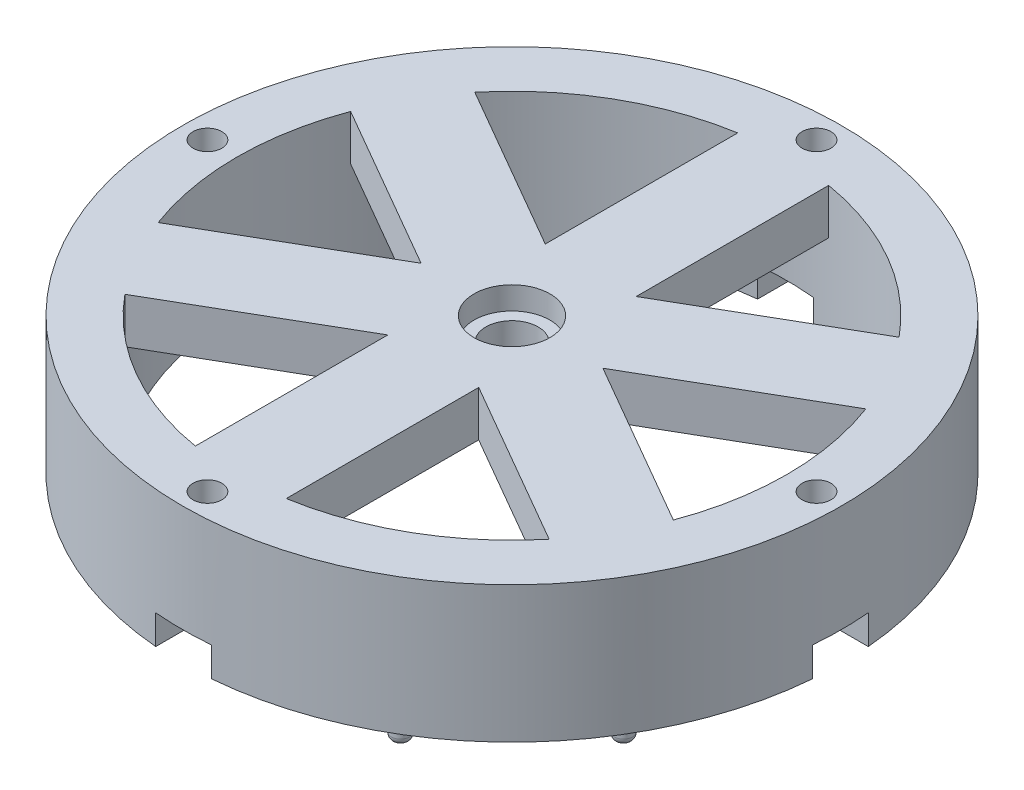
from build123d import *

# Parameters (mm, degrees)
SKETCH1_R               = 72.5
SKETCH1_R_2             = 3.175
BOSS_EXTRUDE1_DEPTH     = 10
SKETCH8_R               = 8.35
CUT_EXTRUDE4_DEPTH      = 5
SKETCH9_R               = 5.75
CUT_EXTRUDE5_DEPTH      = 1
CUT_EXTRUDE5_DEPTH_BACK = 11
SKETCH10_R              = 72.5
SKETCH10_R_2            = 60.5
SKETCH10_R_3            = 3.175
BOSS_EXTRUDE4_DEPTH     = 20
SKETCH11_W              = 32.27284004
SKETCH11_H              = 12.3
SKETCH11_W_2            = 12.3
SKETCH11_H_2            = 32.27284004
CUT_EXTRUDE6_DEPTH      = 6.45
SKETCH12_R              = 2
BOSS_EXTRUDE5_DEPTH     = 5
FILLET1_R               = 1.5


with BuildPart() as part:
    # Sketch1 → Boss-Extrude1 (new body)
    with BuildSketch(Plane(origin=(0, 0, 0), x_dir=(1, 0, 0), z_dir=(0, 1, 0))):
        Circle(SKETCH1_R)
        with Locations((0, 67)):
            Circle(SKETCH1_R_2, mode=Mode.SUBTRACT)
        with Locations((67, 0)):
            Circle(SKETCH1_R_2, mode=Mode.SUBTRACT)
        with Locations((0, -67)):
            Circle(SKETCH1_R_2, mode=Mode.SUBTRACT)
        with Locations((-67, 0)):
            Circle(SKETCH1_R_2, mode=Mode.SUBTRACT)
        with BuildLine():
            Line((10, 17.320508076), (10, 59.667830529))
            ThreePointArc((10, 59.667830529), (30.25, 52.394536929), (46.673857027, 38.494169302))
            Line((46.673857027, 38.494169302), (10, 17.320508076))
        make_face(mode=Mode.SUBTRACT)
        with BuildLine():
            Line((-10, 17.320508076), (-10, 59.667830529))
            ThreePointArc((-10, 59.667830529), (-30.25, 52.394536929), (-46.673857027, 38.494169302))
            Line((-46.673857027, 38.494169302), (-10, 17.320508076))
        make_face(mode=Mode.SUBTRACT)
        with BuildLine():
            Line((-20, 0), (-56.673857027, 21.173661227))
            ThreePointArc((-56.673857027, 21.173661227), (-60.5, 0), (-56.673857027, -21.173661226))
            Line((-56.673857027, -21.173661226), (-20, 0))
        make_face(mode=Mode.SUBTRACT)
        with BuildLine():
            Line((-10, -17.320508076), (-46.673857027, -38.494169302))
            ThreePointArc((-46.673857027, -38.494169302), (-30.25, -52.394536929), (-10, -59.667830529))
            Line((-10, -59.667830529), (-10, -17.320508076))
        make_face(mode=Mode.SUBTRACT)
        with BuildLine():
            Line((10, -17.320508076), (10, -59.667830529))
            ThreePointArc((10, -59.667830529), (30.25, -52.394536929), (46.673857027, -38.494169302))
            Line((46.673857027, -38.494169302), (10, -17.320508076))
        make_face(mode=Mode.SUBTRACT)
        with BuildLine():
            Line((20, 0), (56.673857027, 21.173661227))
            ThreePointArc((56.673857027, 21.173661227), (60.5, 0), (56.673857027, -21.173661226))
            Line((56.673857027, -21.173661226), (20, 0))
        make_face(mode=Mode.SUBTRACT)
    extrude(amount=BOSS_EXTRUDE1_DEPTH)

    # Sketch8 → Cut-Extrude4 (cut)
    with BuildSketch(Plane(origin=(0, 10, 0), x_dir=(1, 0, 0), z_dir=(0, 1, 0))):
        Circle(SKETCH8_R)
    extrude(amount=-CUT_EXTRUDE4_DEPTH, mode=Mode.SUBTRACT)

    # Sketch9 → Cut-Extrude5 (cut, two sides)
    with BuildSketch(Plane(origin=(0, 10, 0), x_dir=(1, 0, 0), z_dir=(0, 1, 0))) as cut_extrude5_sk:
        Circle(SKETCH9_R)
    extrude(amount=CUT_EXTRUDE5_DEPTH, mode=Mode.SUBTRACT)
    extrude(cut_extrude5_sk.sketch, amount=-CUT_EXTRUDE5_DEPTH_BACK, mode=Mode.SUBTRACT)

    # Sketch10 → Boss-Extrude4 (add)
    with BuildSketch(Plane.XZ):
        Circle(SKETCH10_R)
        Circle(SKETCH10_R_2, mode=Mode.SUBTRACT)
        with Locations((0, -67)):
            Circle(SKETCH10_R_3, mode=Mode.SUBTRACT)
        with Locations((-67, 0)):
            Circle(SKETCH10_R_3, mode=Mode.SUBTRACT)
        with Locations((0, 67)):
            Circle(SKETCH10_R_3, mode=Mode.SUBTRACT)
        with Locations((67, 0)):
            Circle(SKETCH10_R_3, mode=Mode.SUBTRACT)
    extrude(amount=BOSS_EXTRUDE4_DEPTH)

    # Sketch11 → Cut-Extrude6 (cut)
    with BuildSketch(Plane.XZ.offset(20)):
        with Locations((-60.5, 0)):
            Rectangle(SKETCH11_W, SKETCH11_H)
        with Locations((0, -60.5)):
            Rectangle(SKETCH11_W_2, SKETCH11_H_2)
        with Locations((0, 60.5)):
            Rectangle(SKETCH11_W_2, SKETCH11_H_2)
        with Locations((60.5, 0)):
            Rectangle(SKETCH11_W, SKETCH11_H)
    extrude(amount=-CUT_EXTRUDE6_DEPTH, mode=Mode.SUBTRACT)

    # Sketch12 → Boss-Extrude5 (add)
    with BuildSketch(Plane.XZ.offset(20)):
        with Locations((33.5, 58.023702054)):
            Circle(SKETCH12_R)
        with Locations((58.023702054, 33.5)):
            Circle(SKETCH12_R)
        with Locations((33.5, -58.023702054)):
            Circle(SKETCH12_R)
        with Locations((58.023702054, -33.5)):
            Circle(SKETCH12_R)
        with Locations((-58.023702054, -33.5)):
            Circle(SKETCH12_R)
        with Locations((-33.5, -58.023702054)):
            Circle(SKETCH12_R)
        with Locations((-33.5, 58.023702054)):
            Circle(SKETCH12_R)
        with Locations((-58.023702054, 33.5)):
            Circle(SKETCH12_R)
    extrude(amount=BOSS_EXTRUDE5_DEPTH)

    # Fillet1
    fillet1_edges = [part.edges().sort_by_distance(p)[0] for p in [
        (31.5, -25, 58.023702054),
        (56.023702054, -25, 33.5),
        (56.023702054, -25, -33.5),
        (31.5, -25, -58.023702054),
        (-35.5, -25, -58.023702054),
        (-60.023702054, -25, -33.5),
        (-60.023702054, -25, 33.5),
        (-35.5, -25, 58.023702054),
    ]]
    fillet(fillet1_edges, radius=FILLET1_R)


solid = part.part
